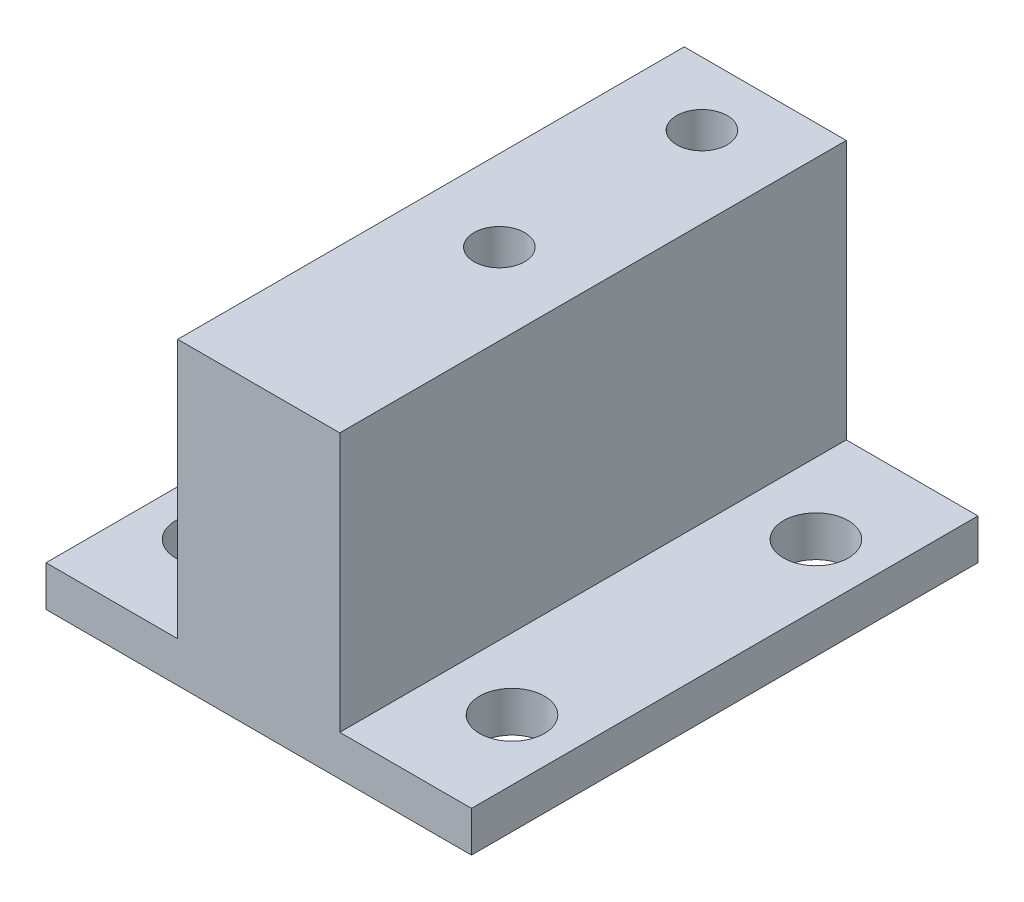
from build123d import *

# Parameters (mm, degrees)
SKETCH1_W                 = 25
SKETCH1_H                 = 25
BOSS_EXTRUDE1_DEPTH       = 14.8
M3_CLEARANCE_HOLE1_D      = 3.2
M3X0_5_TAPPED_HOLE2_D     = 2.5
M3X0_5_TAPPED_HOLE2_DEPTH = 7.5
M3X0_5_TAPPED_HOLE2_TIP   = 0.751075774
SKETCH8_W                 = 8.5
SKETCH8_H                 = 25
CUT_EXTRUDE1_DEPTH        = 9.77
SKETCH9_W                 = 8.5
SKETCH9_H                 = 25
CUT_EXTRUDE2_DEPTH        = 9.77
SKETCH10_W                = 2
SKETCH10_H                = 25
CUT_EXTRUDE3_DEPTH        = 9.77
SKETCH11_W                = 2
SKETCH11_H                = 25
CUT_EXTRUDE4_DEPTH        = 9.77
SKETCH16_W                = 6.5
SKETCH16_H                = 25
CUT_EXTRUDE6_DEPTH        = 3.03
SKETCH17_W                = 6.5
SKETCH17_H                = 25
CUT_EXTRUDE7_DEPTH        = 3.03


with BuildPart() as part:
    # Sketch1 → Boss-Extrude1 (new body)
    with BuildSketch(Plane(origin=(0, 0, 0), x_dir=(1, 0, 0), z_dir=(0, 1, 0))):
        with Locations((12.5, -12.5)):
            Rectangle(SKETCH1_W, SKETCH1_H)
    extrude(amount=BOSS_EXTRUDE1_DEPTH)

    # M3 Clearance Hole1 (through all)
    with Locations(Plane(origin=(5, 14.8, 5), x_dir=(0, 0, 1), z_dir=(0, 1, 0))):
        with Locations((0, 0), (0, 15), (15, 15), (15, 0)):
            Hole(M3_CLEARANCE_HOLE1_D / 2)

    # M3x0.5 Tapped Hole2
    with Locations(Plane(origin=(12.5, 14.8, 3.124233191), x_dir=(0, 0, 1), z_dir=(0, 1, 0))):
        with Locations((0, 0), (10, 0)):
            Hole(M3X0_5_TAPPED_HOLE2_D / 2, depth=M3X0_5_TAPPED_HOLE2_DEPTH)
            with Locations((0, 0, -(M3X0_5_TAPPED_HOLE2_DEPTH + M3X0_5_TAPPED_HOLE2_TIP / 2))):  # 118° drill point
                Cone(0, M3X0_5_TAPPED_HOLE2_D / 2, M3X0_5_TAPPED_HOLE2_TIP, mode=Mode.SUBTRACT)

    # Sketch8 → Cut-Extrude1 (cut)
    with BuildSketch(Plane(origin=(0, 14.8, 0), x_dir=(1, 0, 0), z_dir=(0, 1, 0))):
        with Locations((4.25, -12.5)):
            Rectangle(SKETCH8_W, SKETCH8_H)
    extrude(amount=-CUT_EXTRUDE1_DEPTH, mode=Mode.SUBTRACT)

    # Sketch9 → Cut-Extrude2 (cut)
    with BuildSketch(Plane(origin=(0, 14.8, 0), x_dir=(1, 0, 0), z_dir=(0, 1, 0))):
        with Locations((20.75, -12.5)):
            Rectangle(SKETCH9_W, SKETCH9_H)
    extrude(amount=-CUT_EXTRUDE2_DEPTH, mode=Mode.SUBTRACT)

    # Sketch10 → Cut-Extrude3 (cut)
    with BuildSketch(Plane(origin=(0, 5.03, 0), x_dir=(1, 0, 0), z_dir=(0, 1, 0))):
        with Locations((1, -12.5)):
            Rectangle(SKETCH10_W, SKETCH10_H)
    extrude(amount=-CUT_EXTRUDE3_DEPTH, mode=Mode.SUBTRACT)

    # Sketch11 → Cut-Extrude4 (cut)
    with BuildSketch(Plane(origin=(0, 5.03, 0), x_dir=(1, 0, 0), z_dir=(0, 1, 0))):
        with Locations((24, -12.5)):
            Rectangle(SKETCH11_W, SKETCH11_H)
    extrude(amount=-CUT_EXTRUDE4_DEPTH, mode=Mode.SUBTRACT)

    # Sketch16 → Cut-Extrude6 (cut)
    with BuildSketch(Plane(origin=(0, 5.03, 0), x_dir=(1, 0, 0), z_dir=(0, 1, 0))):
        with Locations((5.25, -12.5)):
            Rectangle(SKETCH16_W, SKETCH16_H)
    extrude(amount=-CUT_EXTRUDE6_DEPTH, mode=Mode.SUBTRACT)

    # Sketch17 → Cut-Extrude7 (cut)
    with BuildSketch(Plane(origin=(0, 5.03, 0), x_dir=(1, 0, 0), z_dir=(0, 1, 0))):
        with Locations((19.75, -12.5)):
            Rectangle(SKETCH17_W, SKETCH17_H)
    extrude(amount=-CUT_EXTRUDE7_DEPTH, mode=Mode.SUBTRACT)


solid = part.part
